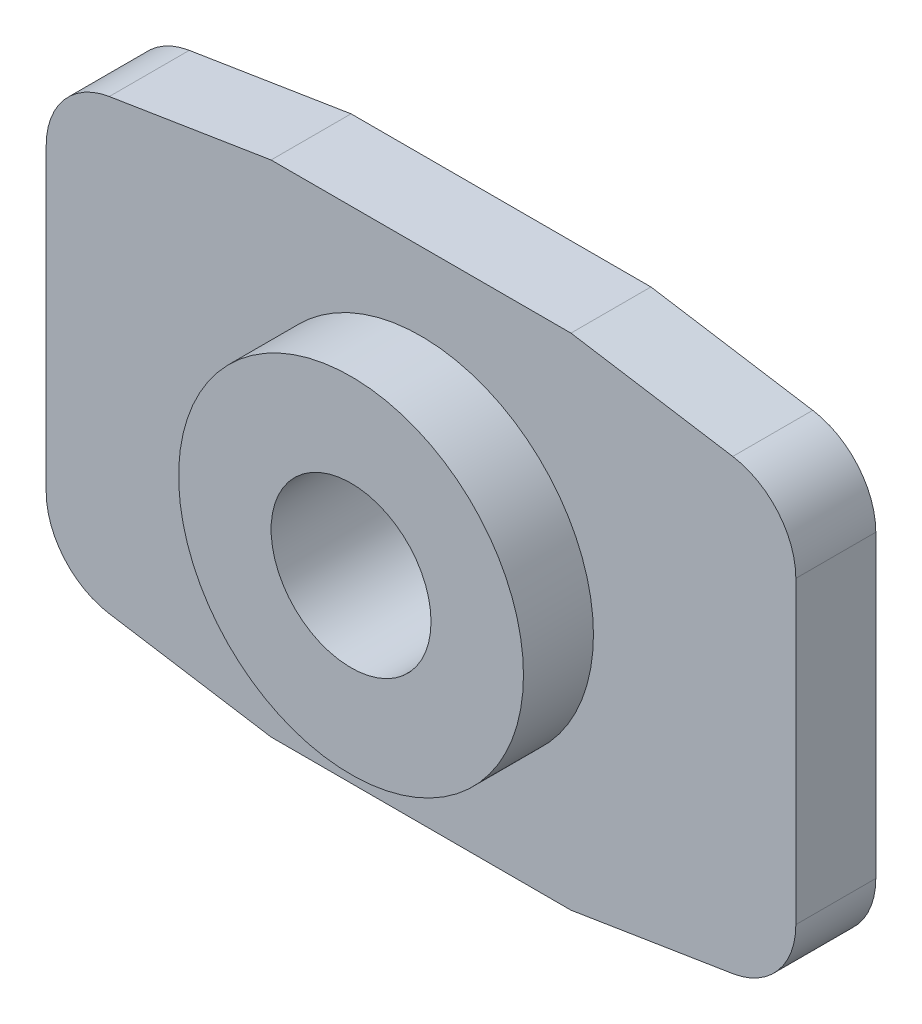
from build123d import *

# Parameters (mm, degrees)
BOSS_EXTRUDE1_DEPTH   = 1.6
SKETCH2_R             = 3.45
BOSS_EXTRUDE2_DEPTH   = 1.4
M5X0_8_TAPPED_HOLE1_D = 3.2


with BuildPart() as part:
    # Sketch1 → Boss-Extrude1 (new body)
    with BuildSketch(Plane.XY):
        with BuildLine():
            Line((-6.237396753, 4.481095129), (-3, 5))
            Line((-3, 5), (3, 5))
            Line((3, 5), (6.237396753, 4.481095129))
            ThreePointArc((6.237396753, 4.481095129), (7.141511088, 3.973114811), (7.5, 3))
            Line((7.5, 3), (7.5, -3))
            ThreePointArc((7.5, -3), (7.141511088, -3.973114811), (6.237396753, -4.481095129))
            Line((6.237396753, -4.481095129), (3, -5))
            Line((3, -5), (-3, -5))
            Line((-3, -5), (-6.237396753, -4.481095129))
            ThreePointArc((-6.237396753, -4.481095129), (-7.141511088, -3.973114811), (-7.5, -3))
            Line((-7.5, -3), (-7.5, 3))
            ThreePointArc((-7.5, 3), (-7.141511088, 3.973114811), (-6.237396753, 4.481095129))
        make_face()
    extrude(amount=BOSS_EXTRUDE1_DEPTH)

    # Sketch2 → Boss-Extrude2 (add)
    with BuildSketch(Plane.XY.offset(1.6)):
        Circle(SKETCH2_R)
    extrude(amount=BOSS_EXTRUDE2_DEPTH)

    # M5x0.8 Tapped Hole1 (through all)
    with Locations(Plane.XY.offset(3)):
        with Locations((0, 0)):
            Hole(M5X0_8_TAPPED_HOLE1_D / 2)


solid = part.part
